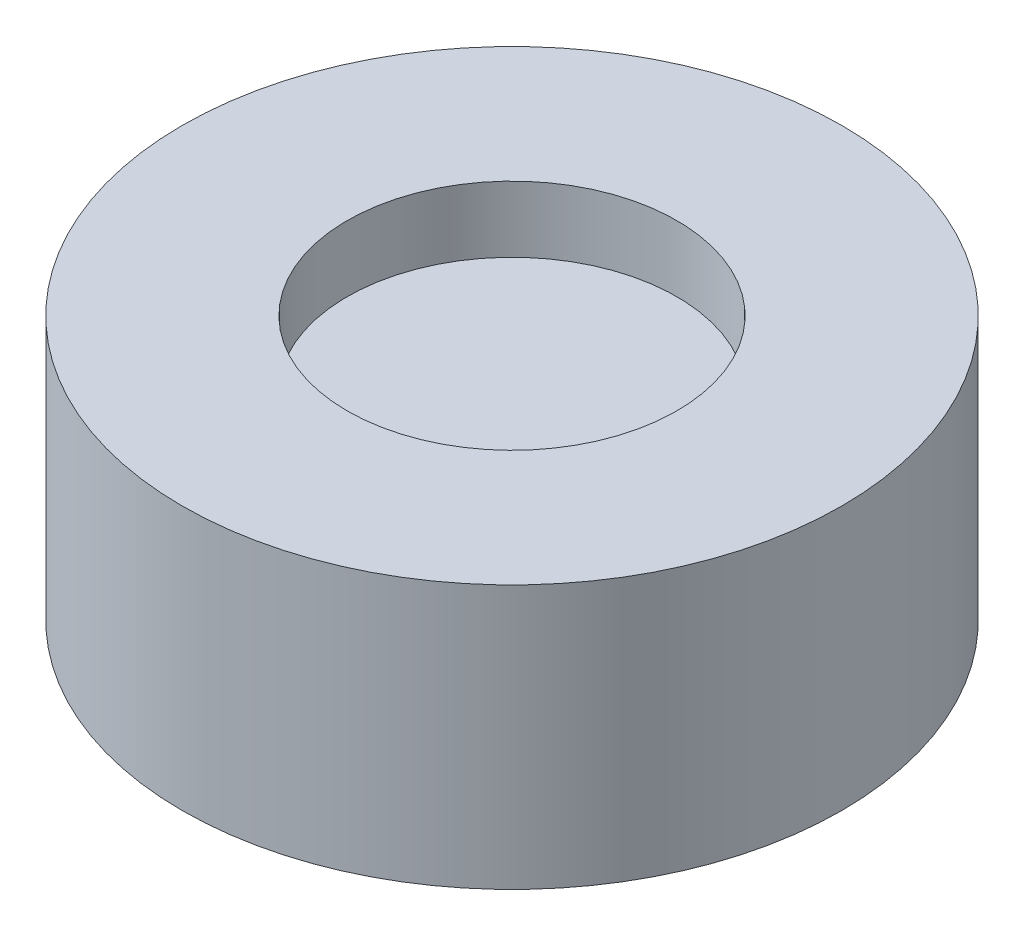
from build123d import *

# Parameters (mm, degrees)
SKETCH1_R           = 10
BOSS_EXTRUDE1_DEPTH = 8
SKETCH2_R           = 5
CUT_EXTRUDE1_DEPTH  = 2
SKETCH3_R           = 1
CUT_EXTRUDE2_DEPTH  = 2
FILLET1_R           = 1


with BuildPart() as part:
    # Sketch1 → Boss-Extrude1 (new body)
    with BuildSketch(Plane(origin=(0, 0, 0), x_dir=(1, 0, 0), z_dir=(0, 1, 0))):
        Circle(SKETCH1_R)
    extrude(amount=BOSS_EXTRUDE1_DEPTH)

    # Sketch2 → Cut-Extrude1 (cut)
    with BuildSketch(Plane(origin=(0, 8, 0), x_dir=(1, 0, 0), z_dir=(0, 1, 0))):
        Circle(SKETCH2_R)
    extrude(amount=-CUT_EXTRUDE1_DEPTH, mode=Mode.SUBTRACT)

    # Sketch3 → Cut-Extrude2 (cut)
    with BuildSketch(Plane.XZ):
        Circle(SKETCH3_R)
    extrude(amount=-CUT_EXTRUDE2_DEPTH, mode=Mode.SUBTRACT)

    # Fillet1
    fillet1_edges = [part.edges().sort_by_distance(p)[0] for p in [
        (-1, 2, 0),
    ]]
    fillet(fillet1_edges, radius=FILLET1_R)


solid = part.part
